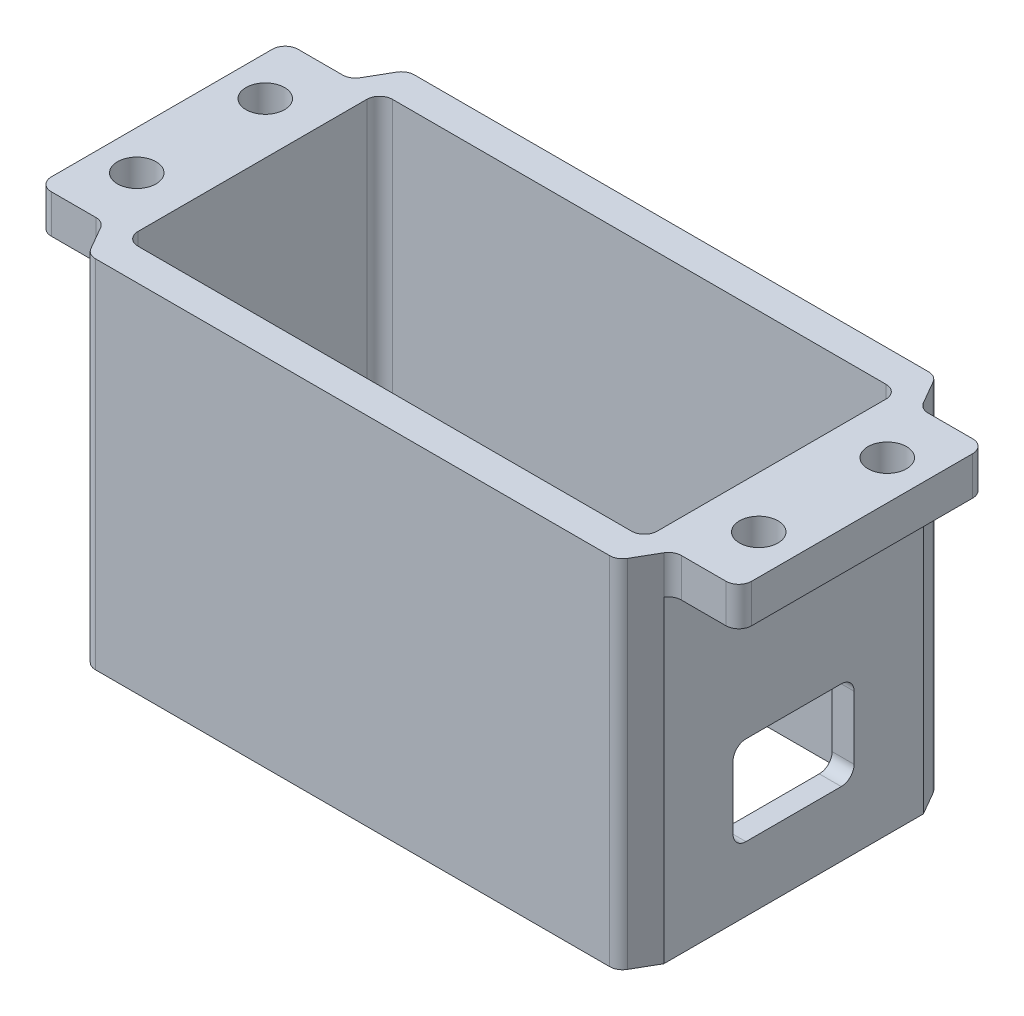
from build123d import *

# Parameters (mm, degrees)
SCHIZZO3_R                   = 1.5
ESTRUSIONE_ESTRUSIONE2_DEPTH = 27.7
TAGLIO_ESTRUSIONE1_REACH     = 56.5
TAGLIO_ESTRUSIONE2_START     = -3
TAGLIO_ESTRUSIONE2_DEPTH     = 24.7


with BuildPart() as part:
    # Schizzo3 → Estrusione-Estrusione2 (new body)
    with BuildSketch(Plane(origin=(0, -1.8, 0), x_dir=(1, 0, 0), z_dir=(0, 1, 0))):
        with BuildLine():
            Line((27.25, -1.6), (27.25, -8.6))
            ThreePointArc((27.25, -8.6), (26.957106781, -9.307106781), (26.25, -9.6))
            Line((26.25, -9.6), (22.777350269, -9.6))
            ThreePointArc((22.777350269, -9.6), (22.277350269, -9.733974596), (21.911324865, -10.1))
            Line((21.911324865, -10.1), (20.872094381, -11.9))
            ThreePointArc((20.872094381, -11.9), (20.506068977, -12.266025404), (20.006068977, -12.4))
            Line((20.006068977, -12.4), (-20.006068977, -12.4))
            ThreePointArc((-20.006068977, -12.4), (-20.506068977, -12.266025404), (-20.872094381, -11.9))
            Line((-20.872094381, -11.9), (-21.911324865, -10.1))
            ThreePointArc((-21.911324865, -10.1), (-22.277350269, -9.733974596), (-22.777350269, -9.6))
            Line((-22.777350269, -9.6), (-26.25, -9.6))
            ThreePointArc((-26.25, -9.6), (-26.957106781, -9.307106781), (-27.25, -8.6))
            Line((-27.25, -8.6), (-27.25, -1.6))
            Line((-27.25, -1.6), (-27.25, 1.6))
            Line((-27.25, 1.6), (-27.25, 8.6))
            ThreePointArc((-27.25, 8.6), (-26.957106781, 9.307106781), (-26.25, 9.6))
            Line((-26.25, 9.6), (-22.777350269, 9.6))
            ThreePointArc((-22.777350269, 9.6), (-22.277350269, 9.733974596), (-21.911324865, 10.1))
            Line((-21.911324865, 10.1), (-20.872094381, 11.9))
            ThreePointArc((-20.872094381, 11.9), (-20.506068977, 12.266025404), (-20.006068977, 12.4))
            Line((-20.006068977, 12.4), (20.006068977, 12.4))
            ThreePointArc((20.006068977, 12.4), (20.506068977, 12.266025404), (20.872094381, 11.9))
            Line((20.872094381, 11.9), (21.911324865, 10.1))
            ThreePointArc((21.911324865, 10.1), (22.277350269, 9.733974596), (22.777350269, 9.6))
            Line((22.777350269, 9.6), (26.25, 9.6))
            ThreePointArc((26.25, 9.6), (26.957106781, 9.307106781), (27.25, 8.6))
            Line((27.25, 8.6), (27.25, 1.6))
            Line((27.25, 1.6), (27.25, -1.6))
        make_face()
        with Locations((24.2, -5)):
            Circle(SCHIZZO3_R, mode=Mode.SUBTRACT)
        with Locations((24.2, 5)):
            Circle(SCHIZZO3_R, mode=Mode.SUBTRACT)
        with Locations((-24.2, 5)):
            Circle(SCHIZZO3_R, mode=Mode.SUBTRACT)
        with Locations((-24.2, -5)):
            Circle(SCHIZZO3_R, mode=Mode.SUBTRACT)
        with BuildLine():
            Line((-19.2, -9.9), (19.2, -9.9))
            ThreePointArc((19.2, -9.9), (19.907106781, -9.607106781), (20.2, -8.9))
            Line((20.2, -8.9), (20.2, 8.9))
            ThreePointArc((20.2, 8.9), (19.907106781, 9.607106781), (19.2, 9.9))
            Line((19.2, 9.9), (-19.2, 9.9))
            ThreePointArc((-19.2, 9.9), (-19.907106781, 9.607106781), (-20.2, 8.9))
            Line((-20.2, 8.9), (-20.2, -8.9))
            ThreePointArc((-20.2, -8.9), (-19.907106781, -9.607106781), (-19.2, -9.9))
        make_face(mode=Mode.SUBTRACT)
    extrude(amount=-ESTRUSIONE_ESTRUSIONE2_DEPTH)

    # Schizzo4 → Taglio-Estrusione1 (cut, up to next)
    with BuildSketch(Plane(origin=(27.25, 0, 0), x_dir=(0, 0, -1), z_dir=(1, 0, 0)), mode=Mode.PRIVATE) as taglio_estrusione1_sk1:
        with BuildLine():
            Line((-3.710237866, -17.5387571), (3.710237866, -17.5387571))
            ThreePointArc((3.710237866, -17.5387571), (4.417344647, -17.831650319), (4.710237866, -18.5387571))
            Line((4.710237866, -18.5387571), (4.710237866, -23.4612429))
            ThreePointArc((4.710237866, -23.4612429), (4.417344647, -24.168349681), (3.710237866, -24.4612429))
            Line((3.710237866, -24.4612429), (-3.710237866, -24.4612429))
            ThreePointArc((-3.710237866, -24.4612429), (-4.417344647, -24.168349681), (-4.710237866, -23.4612429))
            Line((-4.710237866, -23.4612429), (-4.710237866, -18.5387571))
            ThreePointArc((-4.710237866, -18.5387571), (-4.417344647, -17.831650319), (-3.710237866, -17.5387571))
        make_face()
    taglio_estrusione1_tool1 = extrude(taglio_estrusione1_sk1.sketch, amount=-TAGLIO_ESTRUSIONE1_REACH, mode=Mode.PRIVATE) & part.part
    add(taglio_estrusione1_tool1.solids().sort_by_distance((27.25, -21, 0))[0], mode=Mode.SUBTRACT)

    # Schizzo5 → Taglio-Estrusione2 (cut)
    with BuildSketch(Plane(origin=(0, -1.8, 0), x_dir=(1, 0, 0), z_dir=(0, 1, 0)).offset(TAGLIO_ESTRUSIONE2_START)):
        Polygon((27.25, 8.6), (27.25, -8.6), (27.507432363, -11.370727038), (21.911324865, -11.370727038), (21.911324865, -9.6), (21.911324865, 9.6), (21.911324865, 11.665734377), (27.25, 11.503675338), align=None)
    taglio_estrusione2 = extrude(amount=-TAGLIO_ESTRUSIONE2_DEPTH, mode=Mode.SUBTRACT)

    # Specchia1: Taglio-Estrusione2 across plane
    add(taglio_estrusione2.mirror(Plane(origin=(0, 0, 0), x_dir=(0, 0, 1), z_dir=(1, 0, 0))), mode=Mode.SUBTRACT)


solid = part.part
